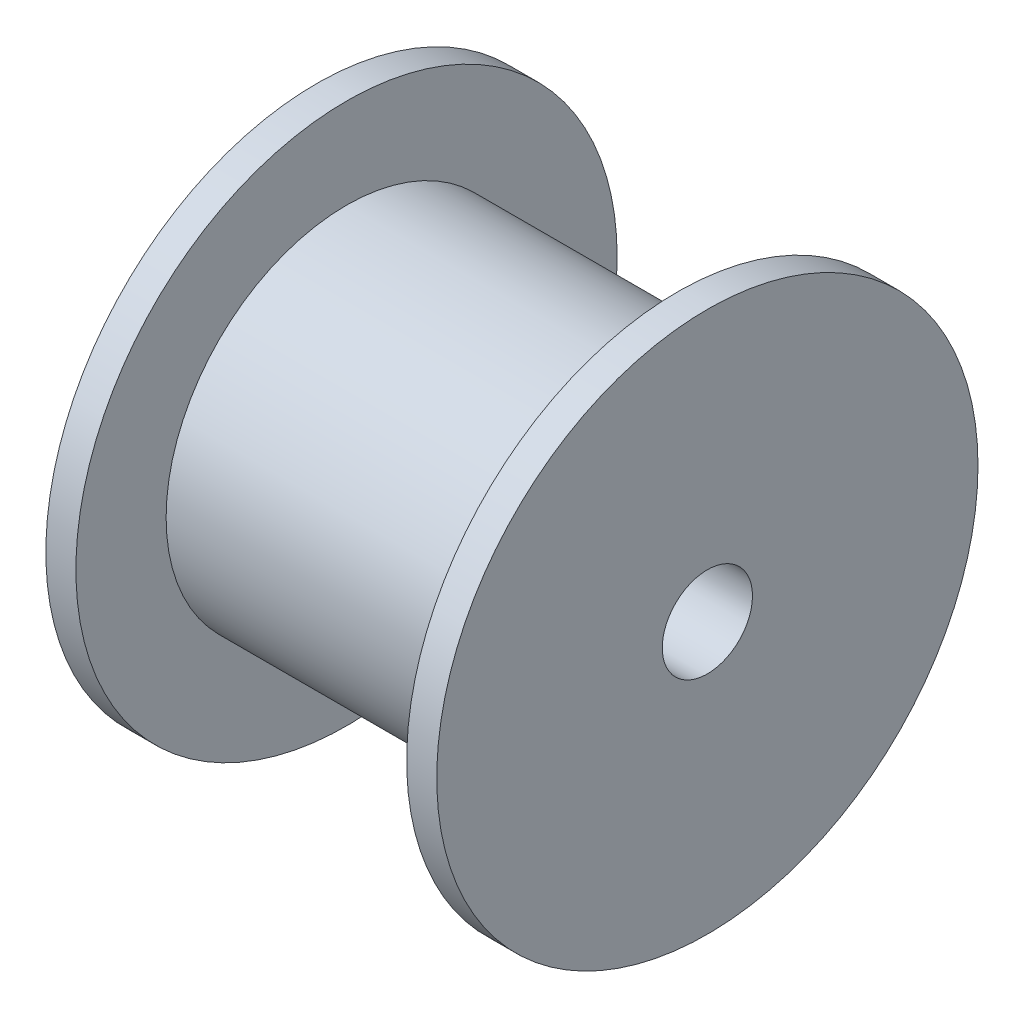
from build123d import *

# Parameters (mm, degrees)
SKETCH1_R           = 9
SKETCH1_R_2         = 1.5
BOSS_EXTRUDE1_DEPTH = 1
SKETCH2_R           = 6
SKETCH2_R_2         = 1.5
BOSS_EXTRUDE2_DEPTH = 11
SKETCH3_R           = 9
SKETCH3_R_2         = 1.5
BOSS_EXTRUDE3_DEPTH = 1


with BuildPart() as part:
    # Sketch1 → Boss-Extrude1 (new body)
    with BuildSketch(Plane(origin=(0, 0, 0), x_dir=(0, 0, -1), z_dir=(1, 0, 0))):
        Circle(SKETCH1_R)
        Circle(SKETCH1_R_2, mode=Mode.SUBTRACT)
    extrude(amount=BOSS_EXTRUDE1_DEPTH)

    # Sketch2 → Boss-Extrude2 (add)
    with BuildSketch(Plane(origin=(1, 0, 0), x_dir=(0, 0, -1), z_dir=(1, 0, 0))):
        Circle(SKETCH2_R)
        Circle(SKETCH2_R_2, mode=Mode.SUBTRACT)
    extrude(amount=BOSS_EXTRUDE2_DEPTH)

    # Sketch3 → Boss-Extrude3 (add)
    with BuildSketch(Plane(origin=(12, 0, 0), x_dir=(0, 0, -1), z_dir=(1, 0, 0))):
        Circle(SKETCH3_R)
        Circle(SKETCH3_R_2, mode=Mode.SUBTRACT)
    extrude(amount=BOSS_EXTRUDE3_DEPTH)


solid = part.part
